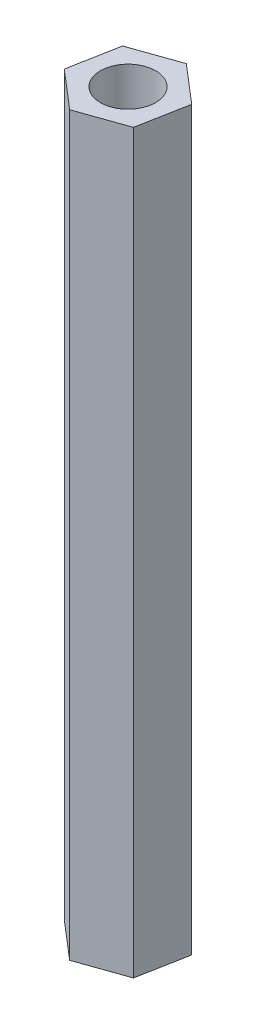
from build123d import *

# Parameters (mm, degrees)
SKETCH_1_R      = 1.5
EXTRUDE_1_DEPTH = 40


with BuildPart() as part:
    # 草图1 → 凸台-拉伸1 (new body)
    with BuildSketch(Plane(origin=(0, 0, 0), x_dir=(1, 0, 0), z_dir=(0, 1, 0))):
        Polygon((2.06091029, -1.765214466), (2.559175715, 0.902193433), (0.498265425, 2.667407899), (-2.06091029, 1.765214466), (-2.559175715, -0.902193433), (-0.498265425, -2.667407899), align=None)
        Circle(SKETCH_1_R, mode=Mode.SUBTRACT)
    extrude(amount=EXTRUDE_1_DEPTH)


solid = part.part
